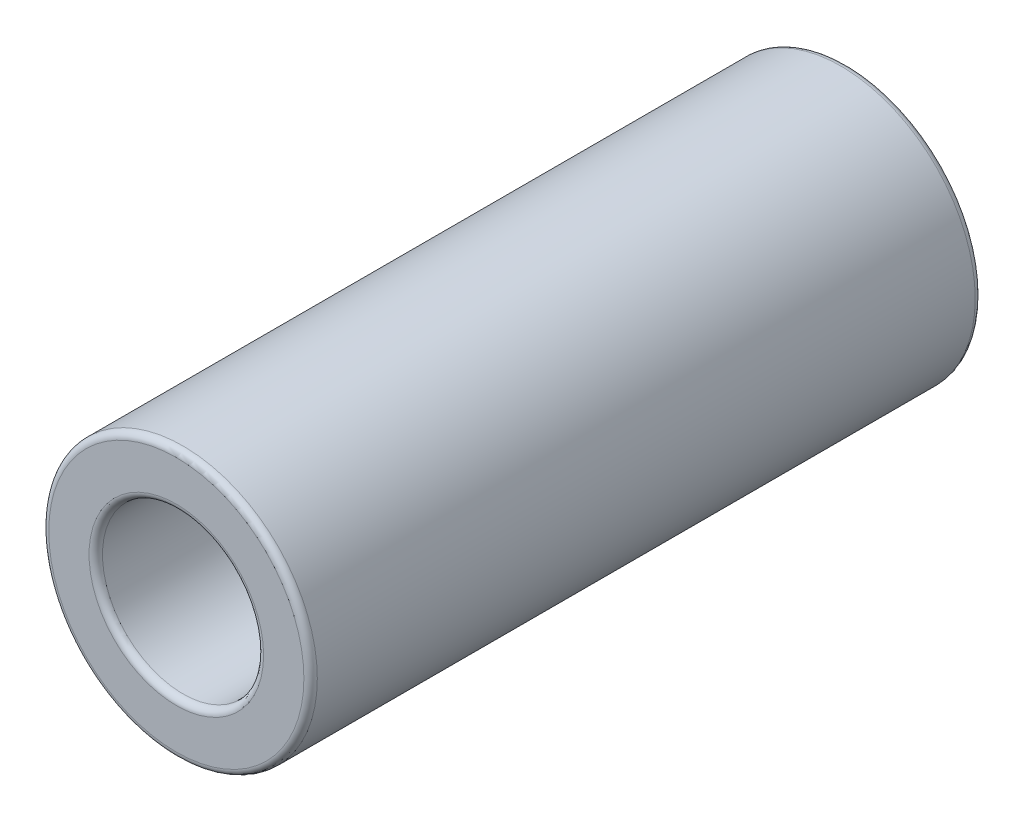
from build123d import *

# Parameters (mm, degrees)
SKETCH1_R           = 5
SKETCH1_R_2         = 3
BOSS_EXTRUDE1_DEPTH = 25
FILLET1_R           = 0.25


with BuildPart() as part:
    # Sketch1 → Boss-Extrude1 (new body)
    with BuildSketch(Plane.XY):
        Circle(SKETCH1_R)
        Circle(SKETCH1_R_2, mode=Mode.SUBTRACT)
    extrude(amount=-BOSS_EXTRUDE1_DEPTH)

    # Fillet1
    fillet1_edges = [part.edges().sort_by_distance(p)[0] for p in [
        (-5, 0, 0),
        (-5, 0, -25),
        (-3, 0, -25),
        (-3, 0, 0),
    ]]
    fillet(fillet1_edges, radius=FILLET1_R)


solid = part.part
